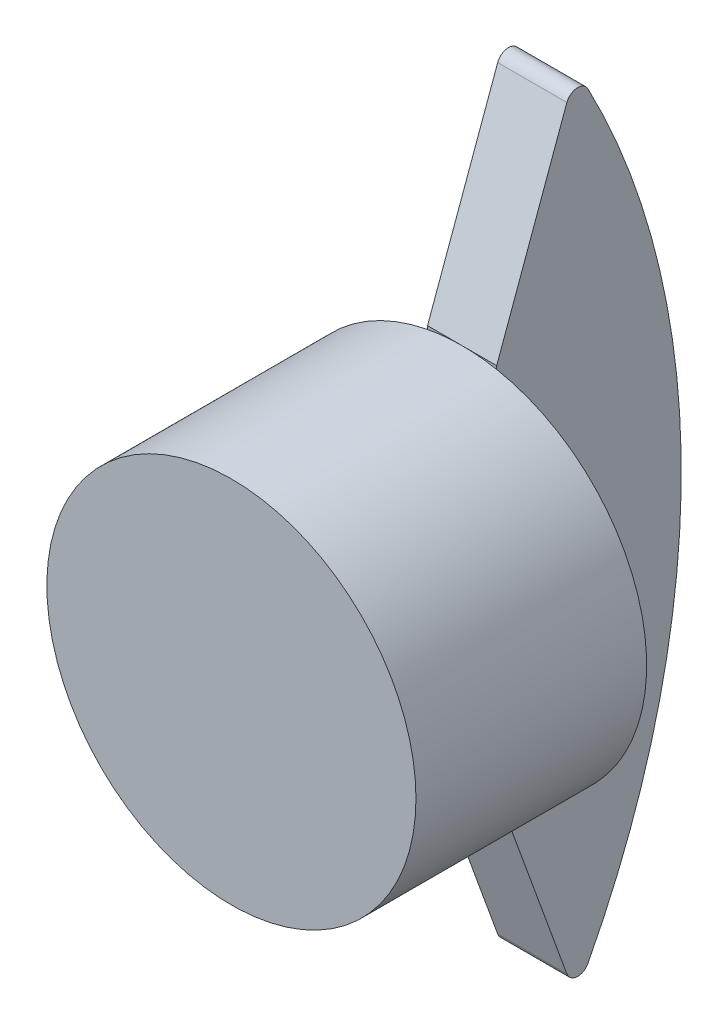
from build123d import *

# Parameters (mm, degrees)
SKETCH_1_R           = 8
EXTRUDE_1_DEPTH      = 10
EXTRUDE_2_DEPTH      = 1.5
EXTRUDE_2_DEPTH_BACK = 1.5
FILLET_1_R           = 0.5


with BuildPart() as part:
    # ｽｹｯﾁ1 → ﾎﾞｽ - 押し出し1 (new body)
    with BuildSketch(Plane.XY):
        Circle(SKETCH_1_R)
    extrude(amount=EXTRUDE_1_DEPTH)

    # ｽｹｯﾁ2 → ﾎﾞｽ - 押し出し2 (add, two sides: drawn at the far end of the back side and taken through both)
    with BuildSketch(Plane(origin=(0, 0, 0), x_dir=(0, 0, -1), z_dir=(1, 0, 0)).offset(-EXTRUDE_2_DEPTH_BACK)):
        with BuildLine():
            Line((0, -8), (0, 8))
            Line((0, 8), (3.420201433, 17.396926208))
            ThreePointArc((3.420201433, 17.396926208), (8, 0), (3.420201433, -17.396926208))
            Line((3.420201433, -17.396926208), (0, -8))
        make_face()
    extrude(amount=EXTRUDE_2_DEPTH + EXTRUDE_2_DEPTH_BACK)

    # ﾌｨﾚｯﾄ1
    fillet_1_edges = [part.edges().sort_by_distance(p)[0] for p in [
        (0, -17.396926208, -3.420201433),
        (0, 17.396926208, -3.420201433),
    ]]
    fillet(fillet_1_edges, radius=FILLET_1_R)


solid = part.part
